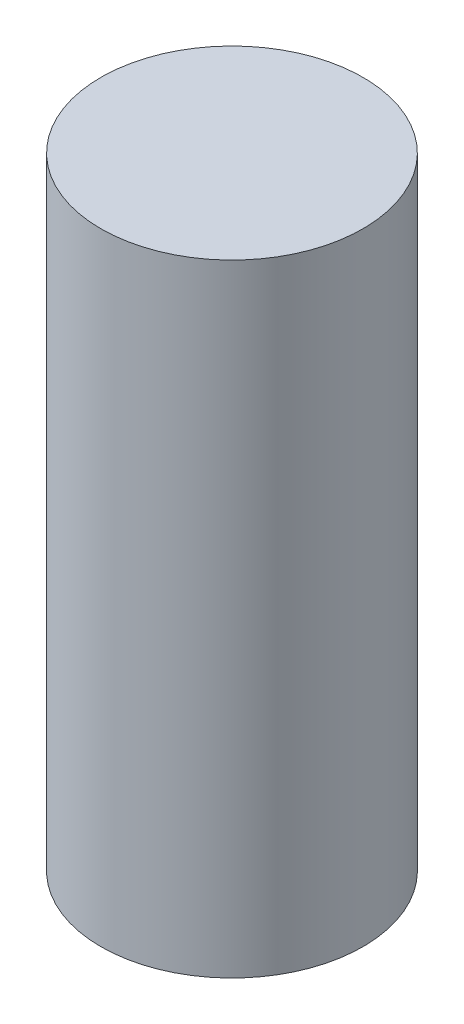
from build123d import *

# Parameters (mm, degrees)
SKETCH1_R           = 6.1595
BOSS_EXTRUDE1_DEPTH = 29.21


with BuildPart() as part:
    # Sketch1 → Boss-Extrude1 (new body)
    with BuildSketch(Plane(origin=(0, 0, 0), x_dir=(1, 0, 0), z_dir=(0, 1, 0))):
        Circle(SKETCH1_R)
    extrude(amount=BOSS_EXTRUDE1_DEPTH)


solid = part.part
